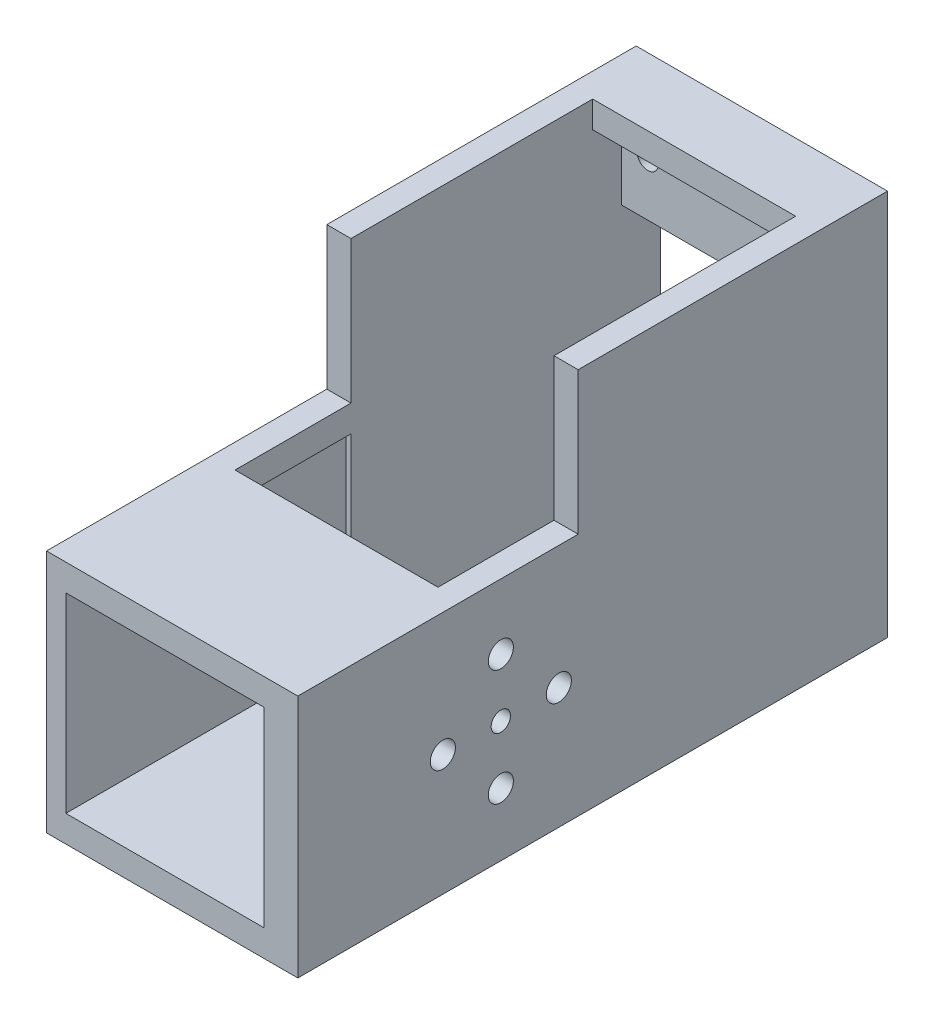
from build123d import *

# Parameters (mm, degrees)
SKETCH1_W               = 26
SKETCH1_H               = 40
BOSS_EXTRUDE1_DEPTH     = 32
SKETCH2_W               = 21
SKETCH2_H               = 34.5
CUT_EXTRUDE1_DEPTH      = 28
SKETCH3_W               = 26
SKETCH3_H               = 25.26
BOSS_EXTRUDE2_DEPTH     = 20
SKETCH4_W               = 22
SKETCH4_H               = 19.76
CUT_EXTRUDE2_DEPTH      = 20
SKETCH5_W               = 21
SKETCH5_H               = 2.75
CUT_EXTRUDE3_DEPTH      = 25
SKETCH6_R               = 1.1
CUT_EXTRUDE4_DEPTH      = 20
SKETCH7_R               = 4
CUT_EXTRUDE5_DEPTH      = 5
SKETCH9_W               = 26
SKETCH9_H               = 25.26
CUT_EXTRUDE9_DEPTH      = 3
SKETCH10_R              = 4.8
SKETCH10_R_2            = 4
BOSS_EXTRUDE3_DEPTH     = 3
CUT_EXTRUDE10_DEPTH     = 5
SKETCH14_W              = 1.5
SKETCH14_H              = 19.76
BOSS_EXTRUDE5_DEPTH     = 17
SKETCH8_R               = 1
SKETCH8_R_2             = 1.3
CUT_EXTRUDE8_DEPTH      = 17
CUT_EXTRUDE8_DEPTH_BACK = 15
SKETCH17_W              = 26
SKETCH17_H              = 25.26
SKETCH17_W_2            = 20.5
SKETCH17_H_2            = 19.76
BOSS_EXTRUDE12_DEPTH    = 12
SKETCH18_W              = 21
SKETCH18_H              = 12
CUT_EXTRUDE11_DEPTH     = 5


with BuildPart() as part:
    # Sketch1 → Boss-Extrude1 (new body)
    with BuildSketch(Plane.XY):
        with Locations((-13, 20)):
            Rectangle(SKETCH1_W, SKETCH1_H)
    extrude(amount=BOSS_EXTRUDE1_DEPTH)

    # Sketch2 → Cut-Extrude1 (cut)
    with BuildSketch(Plane.XY.offset(32)):
        with Locations((-13, 20)):
            Rectangle(SKETCH2_W, SKETCH2_H)
    extrude(amount=-CUT_EXTRUDE1_DEPTH, mode=Mode.SUBTRACT)

    # Sketch3 → Boss-Extrude2 (add)
    with BuildSketch(Plane.XY.offset(32)):
        with Locations((-13, 12.63)):
            Rectangle(SKETCH3_W, SKETCH3_H)
    extrude(amount=BOSS_EXTRUDE2_DEPTH)

    # Sketch4 → Cut-Extrude2 (cut)
    with BuildSketch(Plane.XY.offset(52)):
        with Locations((-13, 12.63)):
            Rectangle(SKETCH4_W, SKETCH4_H)
    extrude(amount=-CUT_EXTRUDE2_DEPTH, mode=Mode.SUBTRACT)

    # Sketch5 → Cut-Extrude3 (cut)
    with BuildSketch(Plane.XY.offset(32)):
        with Locations((-13, 38.625)):
            Rectangle(SKETCH5_W, SKETCH5_H)
    extrude(amount=-CUT_EXTRUDE3_DEPTH, mode=Mode.SUBTRACT)

    # Sketch6 → Cut-Extrude4 (cut)
    with BuildSketch(Plane(origin=(0, 0, 0), x_dir=(-1, 0, 0), z_dir=(0, 0, -1))):
        with Locations((4.8, 4.55)):
            Circle(SKETCH6_R)
        with Locations((20.8, 4.55)):
            Circle(SKETCH6_R)
        with Locations((20.8, 34.55)):
            Circle(SKETCH6_R)
        with Locations((4.8, 34.55)):
            Circle(SKETCH6_R)
    extrude(amount=-CUT_EXTRUDE4_DEPTH, mode=Mode.SUBTRACT)

    # Sketch7 → Cut-Extrude5 (cut)
    with BuildSketch(Plane.ZY.offset(26)):
        with Locations((40, 12.51)):
            Circle(SKETCH7_R)
    extrude(amount=-CUT_EXTRUDE5_DEPTH, mode=Mode.SUBTRACT)

    # Sketch9 → Cut-Extrude9 (cut)
    with BuildSketch(Plane.XY.offset(52)):
        with Locations((-13, 12.63)):
            Rectangle(SKETCH9_W, SKETCH9_H)
    extrude(amount=-CUT_EXTRUDE9_DEPTH, mode=Mode.SUBTRACT)

    # Sketch10 → Boss-Extrude3 (add)
    with BuildSketch(Plane.ZY.offset(26)):
        with Locations((40, 12.51)):
            Circle(SKETCH10_R)
        with Locations((40, 12.51)):
            Circle(SKETCH10_R_2, mode=Mode.SUBTRACT)
    extrude(amount=BOSS_EXTRUDE3_DEPTH)

    # Sketch13 → Cut-Extrude10 (cut, through all)
    with BuildSketch(Plane.XY.offset(4)):
        Polygon((-23.5, 20), (-23.5, 12), (-2.5, 12), (-2.5, 29), (-23.5, 29), align=None)
    extrude(amount=-CUT_EXTRUDE10_DEPTH, mode=Mode.SUBTRACT)

    # Sketch14 → Boss-Extrude5 (add)
    with BuildSketch(Plane.XY.offset(49)):
        with Locations((-2.75, 12.63)):
            Rectangle(SKETCH14_W, SKETCH14_H)
    extrude(amount=-BOSS_EXTRUDE5_DEPTH)

    # Sketch8 → Cut-Extrude8 (cut, two sides)
    with BuildSketch(Plane(origin=(0, 0, 0), x_dir=(0, 0, -1), z_dir=(1, 0, 0))) as cut_extrude8_sk:
        with Locations((-40, 12.51)):
            Circle(SKETCH8_R)
        with Locations((-46, 12.51)):
            Circle(SKETCH8_R_2)
        with Locations((-34, 12.51)):
            Circle(SKETCH8_R_2)
        with Locations((-40, 18.51)):
            Circle(SKETCH8_R_2)
        with Locations((-40, 6.51)):
            Circle(SKETCH8_R_2)
    extrude(amount=CUT_EXTRUDE8_DEPTH, mode=Mode.SUBTRACT)
    extrude(cut_extrude8_sk.sketch, amount=-CUT_EXTRUDE8_DEPTH_BACK, mode=Mode.SUBTRACT)

    # Sketch17 → Boss-Extrude12 (add)
    with BuildSketch(Plane.XY.offset(49)):
        with Locations((-13, 12.63)):
            Rectangle(SKETCH17_W, SKETCH17_H)
        with Locations((-13.75, 12.63)):
            Rectangle(SKETCH17_W_2, SKETCH17_H_2, mode=Mode.SUBTRACT)
    extrude(amount=BOSS_EXTRUDE12_DEPTH)

    # Sketch18 → Cut-Extrude11 (cut)
    with BuildSketch(Plane(origin=(0, 25.26, 0), x_dir=(1, 0, 0), z_dir=(0, 1, 0))):
        with Locations((-13, -38)):
            Rectangle(SKETCH18_W, SKETCH18_H)
    extrude(amount=-CUT_EXTRUDE11_DEPTH, mode=Mode.SUBTRACT)


solid = part.part
